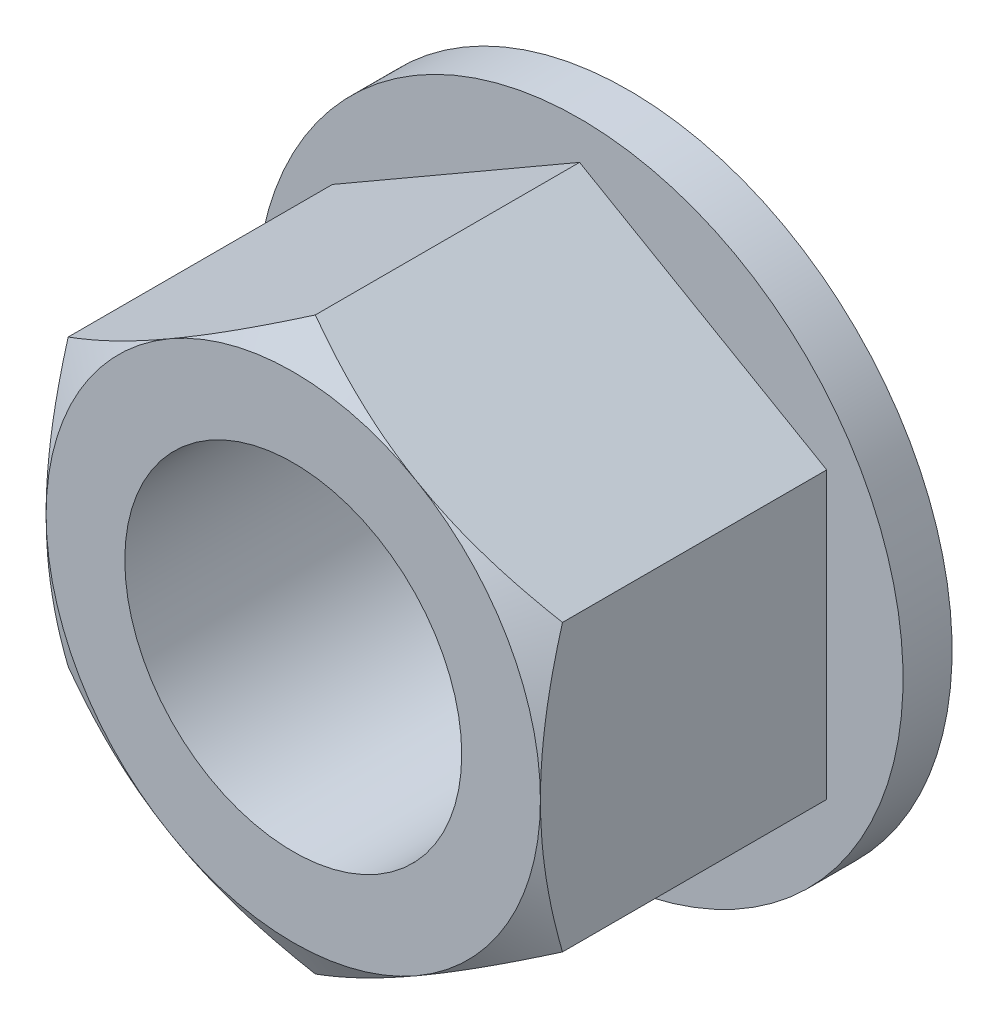
from build123d import *

# Parameters (mm, degrees)
EXTRUDE1_DEPTH          = 2.6924
SKETCH2_OUTSIDE_W       = 34.708
SKETCH2_OUTSIDE_H       = 35.936
SKETCH2_OUTSIDE_R       = 3.96875
CUT_EXTRUDE1_DEPTH      = 6.3848
CUT_EXTRUDE1_TAPER      = 60
SKETCH17_R              = 5.1943
EXTRUDE3_DEPTH          = 0.7874
F_1_4_28_TAPPED_HOLE1_D = 5.4102


with BuildPart() as part:
    # Sketch1 → Extrude1 (new body, symmetric)
    with BuildSketch(Plane.XY):
        Polygon((3.96875, -2.291358881), (3.96875, 2.291358881), (0, 4.582717762), (-3.96875, 2.291358881), (-3.96875, -2.291358881), (0, -4.582717762), align=None)
    extrude(amount=EXTRUDE1_DEPTH, both=True)

    # Sketch2 outside → Cut-Extrude1 (cut, through all)
    with BuildSketch(Plane.XY.offset(2.6924)):
        Rectangle(SKETCH2_OUTSIDE_W, SKETCH2_OUTSIDE_H)
        Circle(SKETCH2_OUTSIDE_R, mode=Mode.SUBTRACT)
    extrude(amount=-CUT_EXTRUDE1_DEPTH, taper=CUT_EXTRUDE1_TAPER, mode=Mode.SUBTRACT)

    # Sketch17 → Extrude3 (add)
    with BuildSketch(Plane(origin=(0, 0, -2.6924), x_dir=(-1, 0, 0), z_dir=(0, 0, -1))):
        Circle(SKETCH17_R)
    extrude(amount=-EXTRUDE3_DEPTH)

    # 1/4-28 Tapped Hole1 (through all)
    with Locations(Plane.XY.offset(2.6924)):
        with Locations((0, 0)):
            Hole(F_1_4_28_TAPPED_HOLE1_D / 2)


solid = part.part
